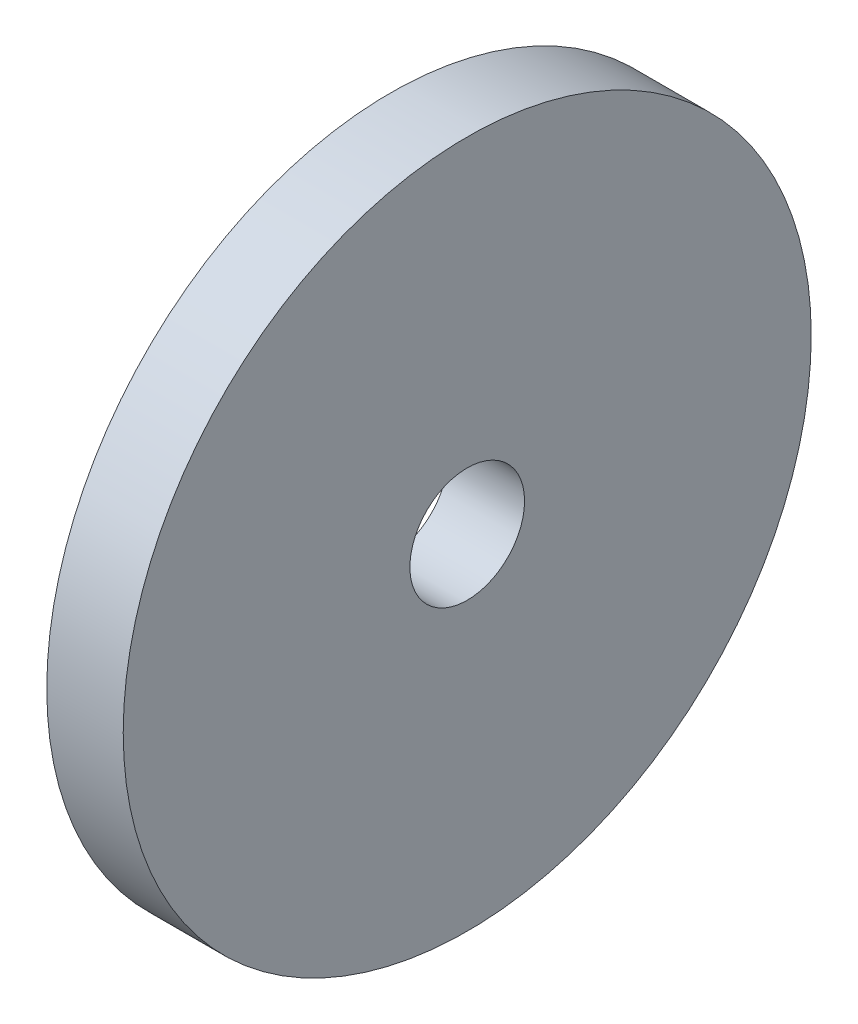
from build123d import *

# Parameters (mm, degrees)
SKETCH1_R           = 9
BOSS_EXTRUDE1_DEPTH = 2
SKETCH2_R           = 1.5
CUT_EXTRUDE1_DEPTH  = 3


with BuildPart() as part:
    # Sketch1 → Boss-Extrude1 (new body)
    with BuildSketch(Plane(origin=(0, 0, 0), x_dir=(0, 0, -1), z_dir=(1, 0, 0))):
        Circle(SKETCH1_R)
    extrude(amount=BOSS_EXTRUDE1_DEPTH)

    # Sketch2 → Cut-Extrude1 (cut, through all)
    with BuildSketch(Plane(origin=(2, 0, 0), x_dir=(0, 0, -1), z_dir=(1, 0, 0))):
        Circle(SKETCH2_R)
    extrude(amount=-CUT_EXTRUDE1_DEPTH, mode=Mode.SUBTRACT)


solid = part.part
